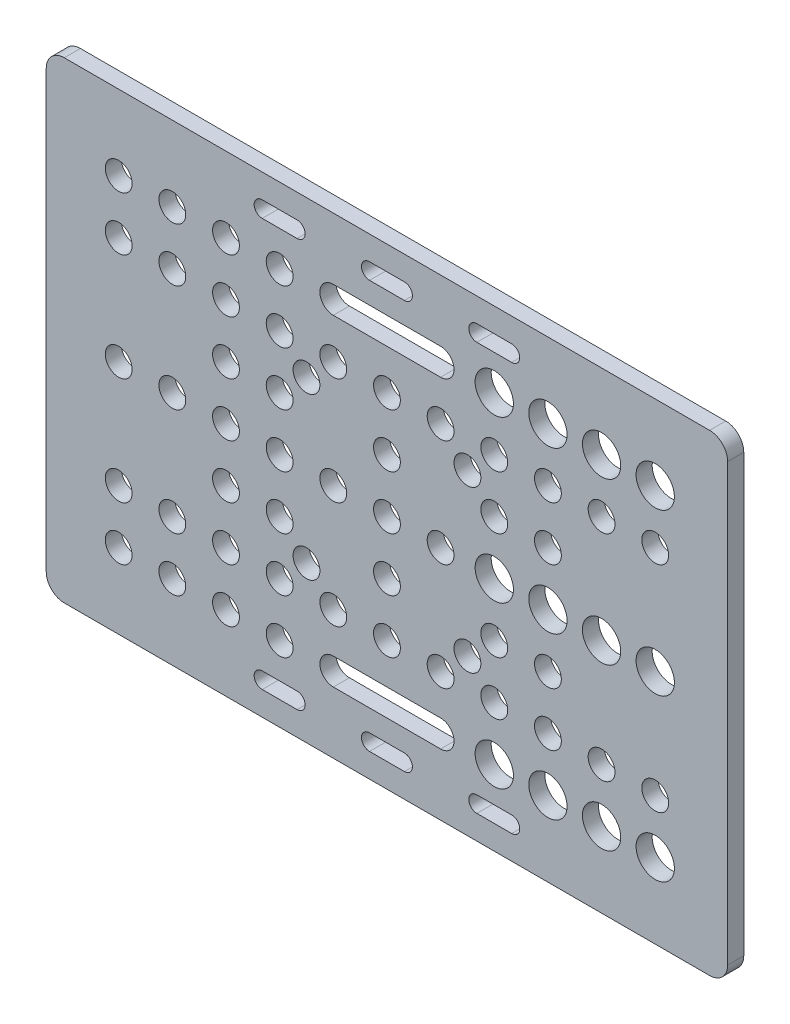
from build123d import *

# Parameters (mm, degrees)
SKETCH1_R           = 2.5
SKETCH1_R_2         = 3.57
BOSS_EXTRUDE1_DEPTH = 1.5


with BuildPart() as part:
    # Sketch1 → Boss-Extrude1 (new body, symmetric)
    with BuildSketch(Plane.XY):
        with BuildLine():
            Line((-60.14, -44), (60.14, -44))
            ThreePointArc((60.14, -44), (62.515878785, -43.015878785), (63.5, -40.64))
            Line((63.5, -40.64), (63.5, 40.64))
            ThreePointArc((63.5, 40.64), (62.515878785, 43.015878785), (60.14, 44))
            Line((60.14, 44), (-60.14, 44))
            ThreePointArc((-60.14, 44), (-62.515878785, 43.015878785), (-63.5, 40.64))
            Line((-63.5, 40.64), (-63.5, -40.64))
            ThreePointArc((-63.5, -40.64), (-62.515878785, -43.015878785), (-60.14, -44))
        make_face()
        with Locations((0, -20)):
            Circle(SKETCH1_R, mode=Mode.SUBTRACT)
        with Locations((10, -20)):
            Circle(SKETCH1_R, mode=Mode.SUBTRACT)
        with Locations((20, -20)):
            Circle(SKETCH1_R, mode=Mode.SUBTRACT)
        with Locations((30, -20)):
            Circle(SKETCH1_R, mode=Mode.SUBTRACT)
        with Locations((40, -20)):
            Circle(SKETCH1_R, mode=Mode.SUBTRACT)
        with Locations((50, -20)):
            Circle(SKETCH1_R, mode=Mode.SUBTRACT)
        with Locations((-10, -20)):
            Circle(SKETCH1_R, mode=Mode.SUBTRACT)
        with Locations((-20, -20)):
            Circle(SKETCH1_R, mode=Mode.SUBTRACT)
        with Locations((-30, -20)):
            Circle(SKETCH1_R, mode=Mode.SUBTRACT)
        with Locations((-40, -20)):
            Circle(SKETCH1_R, mode=Mode.SUBTRACT)
        with Locations((-50, -20)):
            Circle(SKETCH1_R, mode=Mode.SUBTRACT)
        with Locations((-50, -30)):
            Circle(SKETCH1_R, mode=Mode.SUBTRACT)
        with Locations((-40, -30)):
            Circle(SKETCH1_R, mode=Mode.SUBTRACT)
        with Locations((-30, -30)):
            Circle(SKETCH1_R, mode=Mode.SUBTRACT)
        with Locations((-20, -30)):
            Circle(SKETCH1_R, mode=Mode.SUBTRACT)
        with Locations((50, -30)):
            Circle(SKETCH1_R_2, mode=Mode.SUBTRACT)
        with Locations((40, -30)):
            Circle(SKETCH1_R_2, mode=Mode.SUBTRACT)
        with Locations((30, -30)):
            Circle(SKETCH1_R_2, mode=Mode.SUBTRACT)
        with Locations((20, -30)):
            Circle(SKETCH1_R_2, mode=Mode.SUBTRACT)
        with Locations((-50, 0)):
            Circle(SKETCH1_R, mode=Mode.SUBTRACT)
        with Locations((-40, 0)):
            Circle(SKETCH1_R, mode=Mode.SUBTRACT)
        with Locations((-30, 0)):
            Circle(SKETCH1_R, mode=Mode.SUBTRACT)
        with Locations((-20, 0)):
            Circle(SKETCH1_R, mode=Mode.SUBTRACT)
        with Locations((-10, 0)):
            Circle(SKETCH1_R, mode=Mode.SUBTRACT)
        Circle(SKETCH1_R, mode=Mode.SUBTRACT)
        with Locations((10, 0)):
            Circle(SKETCH1_R, mode=Mode.SUBTRACT)
        with Locations((20, 0)):
            Circle(SKETCH1_R_2, mode=Mode.SUBTRACT)
        with Locations((30, 0)):
            Circle(SKETCH1_R_2, mode=Mode.SUBTRACT)
        with Locations((40, 0)):
            Circle(SKETCH1_R_2, mode=Mode.SUBTRACT)
        with Locations((50, 0)):
            Circle(SKETCH1_R_2, mode=Mode.SUBTRACT)
        with Locations((-30, -10)):
            Circle(SKETCH1_R, mode=Mode.SUBTRACT)
        with Locations((-20, -10)):
            Circle(SKETCH1_R, mode=Mode.SUBTRACT)
        with Locations((20, -10)):
            Circle(SKETCH1_R, mode=Mode.SUBTRACT)
        with Locations((30, -10)):
            Circle(SKETCH1_R, mode=Mode.SUBTRACT)
        with Locations((0, -10)):
            Circle(SKETCH1_R, mode=Mode.SUBTRACT)
        with Locations((-15, -15)):
            Circle(SKETCH1_R, mode=Mode.SUBTRACT)
        with Locations((15, -15)):
            Circle(SKETCH1_R, mode=Mode.SUBTRACT)
        with Locations((15, 15)):
            Circle(SKETCH1_R, mode=Mode.SUBTRACT)
        with Locations((-15, 15)):
            Circle(SKETCH1_R, mode=Mode.SUBTRACT)
        with Locations((0, 10)):
            Circle(SKETCH1_R, mode=Mode.SUBTRACT)
        with Locations((30, 10)):
            Circle(SKETCH1_R, mode=Mode.SUBTRACT)
        with Locations((20, 10)):
            Circle(SKETCH1_R, mode=Mode.SUBTRACT)
        with Locations((-20, 10)):
            Circle(SKETCH1_R, mode=Mode.SUBTRACT)
        with Locations((-30, 10)):
            Circle(SKETCH1_R, mode=Mode.SUBTRACT)
        with Locations((20, 30)):
            Circle(SKETCH1_R_2, mode=Mode.SUBTRACT)
        with Locations((30, 30)):
            Circle(SKETCH1_R_2, mode=Mode.SUBTRACT)
        with Locations((40, 30)):
            Circle(SKETCH1_R_2, mode=Mode.SUBTRACT)
        with Locations((50, 30)):
            Circle(SKETCH1_R_2, mode=Mode.SUBTRACT)
        with Locations((-20, 30)):
            Circle(SKETCH1_R, mode=Mode.SUBTRACT)
        with Locations((-30, 30)):
            Circle(SKETCH1_R, mode=Mode.SUBTRACT)
        with Locations((-40, 30)):
            Circle(SKETCH1_R, mode=Mode.SUBTRACT)
        with Locations((-50, 30)):
            Circle(SKETCH1_R, mode=Mode.SUBTRACT)
        with Locations((-50, 20)):
            Circle(SKETCH1_R, mode=Mode.SUBTRACT)
        with Locations((-40, 20)):
            Circle(SKETCH1_R, mode=Mode.SUBTRACT)
        with Locations((-30, 20)):
            Circle(SKETCH1_R, mode=Mode.SUBTRACT)
        with Locations((-20, 20)):
            Circle(SKETCH1_R, mode=Mode.SUBTRACT)
        with Locations((-10, 20)):
            Circle(SKETCH1_R, mode=Mode.SUBTRACT)
        with Locations((50, 20)):
            Circle(SKETCH1_R, mode=Mode.SUBTRACT)
        with Locations((40, 20)):
            Circle(SKETCH1_R, mode=Mode.SUBTRACT)
        with Locations((30, 20)):
            Circle(SKETCH1_R, mode=Mode.SUBTRACT)
        with Locations((20, 20)):
            Circle(SKETCH1_R, mode=Mode.SUBTRACT)
        with Locations((10, 20)):
            Circle(SKETCH1_R, mode=Mode.SUBTRACT)
        with Locations((0, 20)):
            Circle(SKETCH1_R, mode=Mode.SUBTRACT)
        with BuildLine():
            Line((-10, -27.5), (10, -27.5))
            ThreePointArc((10, -27.5), (12.5, -30), (10, -32.5))
            Line((10, -32.5), (-10, -32.5))
            ThreePointArc((-10, -32.5), (-12.5, -30), (-10, -27.5))
        make_face(mode=Mode.SUBTRACT)
        with BuildLine():
            Line((-23.25, -36.52), (-16.75, -36.52))
            ThreePointArc((-16.75, -36.52), (-15.25, -38.02), (-16.75, -39.52))
            Line((-16.75, -39.52), (-23.25, -39.52))
            ThreePointArc((-23.25, -39.52), (-24.75, -38.02), (-23.25, -36.52))
        make_face(mode=Mode.SUBTRACT)
        with BuildLine():
            Line((-3.25, -36.52), (3.25, -36.52))
            ThreePointArc((3.25, -36.52), (4.75, -38.02), (3.25, -39.52))
            Line((3.25, -39.52), (-3.25, -39.52))
            ThreePointArc((-3.25, -39.52), (-4.75, -38.02), (-3.25, -36.52))
        make_face(mode=Mode.SUBTRACT)
        with BuildLine():
            Line((16.75, -36.52), (23.25, -36.52))
            ThreePointArc((23.25, -36.52), (24.75, -38.02), (23.25, -39.52))
            Line((23.25, -39.52), (16.75, -39.52))
            ThreePointArc((16.75, -39.52), (15.25, -38.02), (16.75, -36.52))
        make_face(mode=Mode.SUBTRACT)
        with BuildLine():
            Line((-10, 27.5), (10, 27.5))
            ThreePointArc((10, 27.5), (12.5, 30), (10, 32.5))
            Line((10, 32.5), (-10, 32.5))
            ThreePointArc((-10, 32.5), (-12.5, 30), (-10, 27.5))
        make_face(mode=Mode.SUBTRACT)
        with BuildLine():
            Line((-23.25, 36.52), (-16.75, 36.52))
            ThreePointArc((-16.75, 36.52), (-15.25, 38.02), (-16.75, 39.52))
            Line((-16.75, 39.52), (-23.25, 39.52))
            ThreePointArc((-23.25, 39.52), (-24.75, 38.02), (-23.25, 36.52))
        make_face(mode=Mode.SUBTRACT)
        with BuildLine():
            Line((-3.25, 36.52), (3.25, 36.52))
            ThreePointArc((3.25, 36.52), (4.75, 38.02), (3.25, 39.52))
            Line((3.25, 39.52), (-3.25, 39.52))
            ThreePointArc((-3.25, 39.52), (-4.75, 38.02), (-3.25, 36.52))
        make_face(mode=Mode.SUBTRACT)
        with BuildLine():
            Line((16.75, 36.52), (23.25, 36.52))
            ThreePointArc((23.25, 36.52), (24.75, 38.02), (23.25, 39.52))
            Line((23.25, 39.52), (16.75, 39.52))
            ThreePointArc((16.75, 39.52), (15.25, 38.02), (16.75, 36.52))
        make_face(mode=Mode.SUBTRACT)
    extrude(amount=BOSS_EXTRUDE1_DEPTH, both=True)


solid = part.part
